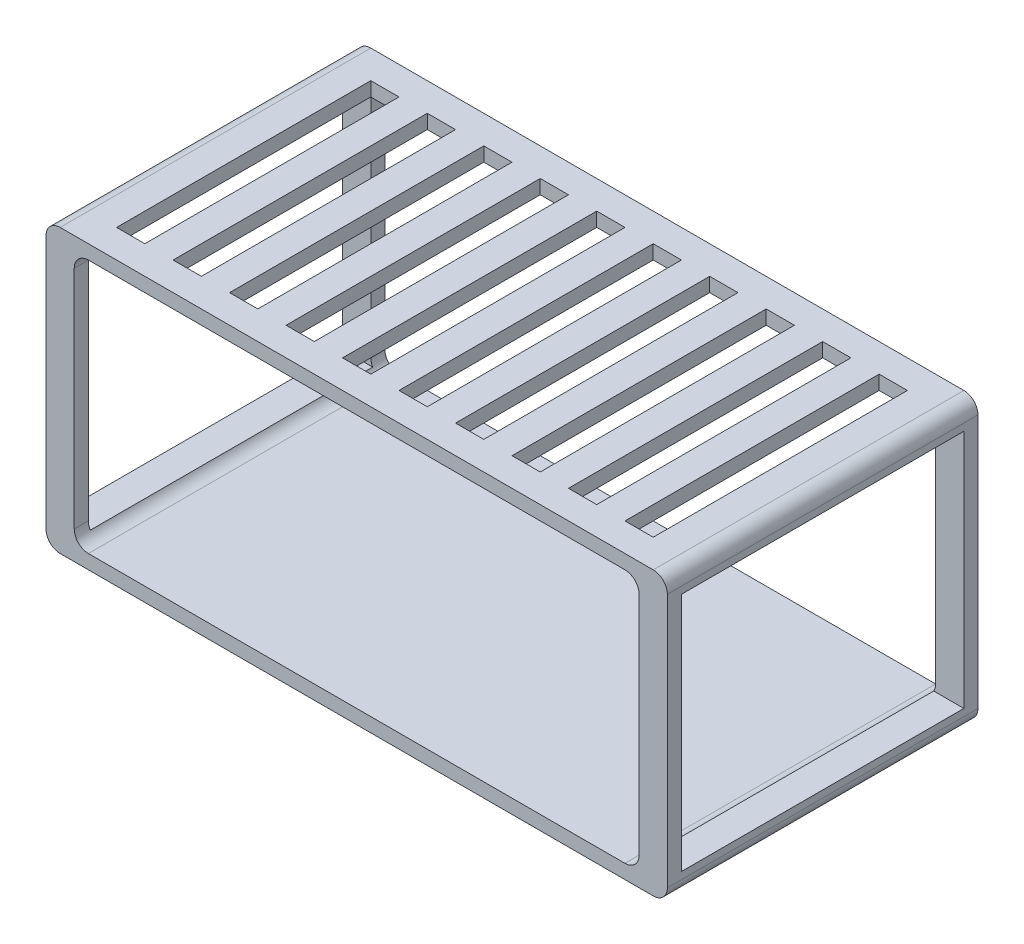
from build123d import *

# Parameters (mm, degrees)
SKETCH1_W               = 2200
SKETCH1_H               = 1000
BOSS_EXTRUDE1_DEPTH     = 1100
SKETCH2_W               = 2000
SKETCH2_H               = 900
CUT_EXTRUDE1_DEPTH      = 1
CUT_EXTRUDE1_DEPTH_BACK = 1101
FILLET1_R               = 50
CUT_EXTRUDE2_REACH      = 1002
SKETCH3_W               = 100
SKETCH3_H               = 900
SKETCH4_W               = 1000
SKETCH4_H               = 850
CUT_EXTRUDE3_DEPTH      = 1
CUT_EXTRUDE3_DEPTH_BACK = 2201


with BuildPart() as part:
    # Sketch1 → Boss-Extrude1 (new body)
    with BuildSketch(Plane.XY):
        with Locations((-1100, 500)):
            Rectangle(SKETCH1_W, SKETCH1_H)
    extrude(amount=BOSS_EXTRUDE1_DEPTH)

    # Sketch2 → Cut-Extrude1 (cut, two sides)
    with BuildSketch(Plane.XY.offset(1100)) as cut_extrude1_sk:
        with Locations((-1100, 500)):
            Rectangle(SKETCH2_W, SKETCH2_H)
    extrude(amount=CUT_EXTRUDE1_DEPTH, mode=Mode.SUBTRACT)
    extrude(cut_extrude1_sk.sketch, amount=-CUT_EXTRUDE1_DEPTH_BACK, mode=Mode.SUBTRACT)

    # Fillet1
    fillet1_edges = [part.edges().sort_by_distance(p)[0] for p in [
        (-2100, 50, 550),
        (-2100, 950, 550),
        (-100, 950, 550),
        (-100, 50, 550),
        (0, 0, 550),
        (-2200, 0, 550),
        (-2200, 1000, 550),
        (0, 1000, 550),
    ]]
    fillet(fillet1_edges, radius=FILLET1_R)

    # Sketch3 → Cut-Extrude2 (cut, up to next)
    with BuildSketch(Plane(origin=(0, 1000, 0), x_dir=(1, 0, 0), z_dir=(0, 1, 0)), mode=Mode.PRIVATE) as cut_extrude2_sk1:
        with Locations((-2000, -550)):
            Rectangle(SKETCH3_W, SKETCH3_H)
    cut_extrude2_tool1 = extrude(cut_extrude2_sk1.sketch, amount=-CUT_EXTRUDE2_REACH, mode=Mode.PRIVATE) & part.part
    add(cut_extrude2_tool1.solids().sort_by_distance((-2000, 1000, 550))[0], mode=Mode.SUBTRACT)
    # Sketch3 → Cut-Extrude2 (cut, up to next)
    with BuildSketch(Plane(origin=(0, 1000, 0), x_dir=(1, 0, 0), z_dir=(0, 1, 0)), mode=Mode.PRIVATE) as cut_extrude2_sk2:
        with Locations((-1800, -550)):
            Rectangle(SKETCH3_W, SKETCH3_H)
    cut_extrude2_tool2 = extrude(cut_extrude2_sk2.sketch, amount=-CUT_EXTRUDE2_REACH, mode=Mode.PRIVATE) & part.part
    add(cut_extrude2_tool2.solids().sort_by_distance((-1800, 1000, 550))[0], mode=Mode.SUBTRACT)
    # Sketch3 → Cut-Extrude2 (cut, up to next)
    with BuildSketch(Plane(origin=(0, 1000, 0), x_dir=(1, 0, 0), z_dir=(0, 1, 0)), mode=Mode.PRIVATE) as cut_extrude2_sk3:
        with Locations((-1600, -550)):
            Rectangle(SKETCH3_W, SKETCH3_H)
    cut_extrude2_tool3 = extrude(cut_extrude2_sk3.sketch, amount=-CUT_EXTRUDE2_REACH, mode=Mode.PRIVATE) & part.part
    add(cut_extrude2_tool3.solids().sort_by_distance((-1600, 1000, 550))[0], mode=Mode.SUBTRACT)
    # Sketch3 → Cut-Extrude2 (cut, up to next)
    with BuildSketch(Plane(origin=(0, 1000, 0), x_dir=(1, 0, 0), z_dir=(0, 1, 0)), mode=Mode.PRIVATE) as cut_extrude2_sk4:
        with Locations((-1400, -550)):
            Rectangle(SKETCH3_W, SKETCH3_H)
    cut_extrude2_tool4 = extrude(cut_extrude2_sk4.sketch, amount=-CUT_EXTRUDE2_REACH, mode=Mode.PRIVATE) & part.part
    add(cut_extrude2_tool4.solids().sort_by_distance((-1400, 1000, 550))[0], mode=Mode.SUBTRACT)
    # Sketch3 → Cut-Extrude2 (cut, up to next)
    with BuildSketch(Plane(origin=(0, 1000, 0), x_dir=(1, 0, 0), z_dir=(0, 1, 0)), mode=Mode.PRIVATE) as cut_extrude2_sk5:
        with Locations((-1200, -550)):
            Rectangle(SKETCH3_W, SKETCH3_H)
    cut_extrude2_tool5 = extrude(cut_extrude2_sk5.sketch, amount=-CUT_EXTRUDE2_REACH, mode=Mode.PRIVATE) & part.part
    add(cut_extrude2_tool5.solids().sort_by_distance((-1200, 1000, 550))[0], mode=Mode.SUBTRACT)
    # Sketch3 → Cut-Extrude2 (cut, up to next)
    with BuildSketch(Plane(origin=(0, 1000, 0), x_dir=(1, 0, 0), z_dir=(0, 1, 0)), mode=Mode.PRIVATE) as cut_extrude2_sk6:
        with Locations((-1000, -550)):
            Rectangle(SKETCH3_W, SKETCH3_H)
    cut_extrude2_tool6 = extrude(cut_extrude2_sk6.sketch, amount=-CUT_EXTRUDE2_REACH, mode=Mode.PRIVATE) & part.part
    add(cut_extrude2_tool6.solids().sort_by_distance((-1000, 1000, 550))[0], mode=Mode.SUBTRACT)
    # Sketch3 → Cut-Extrude2 (cut, up to next)
    with BuildSketch(Plane(origin=(0, 1000, 0), x_dir=(1, 0, 0), z_dir=(0, 1, 0)), mode=Mode.PRIVATE) as cut_extrude2_sk7:
        with Locations((-800, -550)):
            Rectangle(SKETCH3_W, SKETCH3_H)
    cut_extrude2_tool7 = extrude(cut_extrude2_sk7.sketch, amount=-CUT_EXTRUDE2_REACH, mode=Mode.PRIVATE) & part.part
    add(cut_extrude2_tool7.solids().sort_by_distance((-800, 1000, 550))[0], mode=Mode.SUBTRACT)
    # Sketch3 → Cut-Extrude2 (cut, up to next)
    with BuildSketch(Plane(origin=(0, 1000, 0), x_dir=(1, 0, 0), z_dir=(0, 1, 0)), mode=Mode.PRIVATE) as cut_extrude2_sk8:
        with Locations((-600, -550)):
            Rectangle(SKETCH3_W, SKETCH3_H)
    cut_extrude2_tool8 = extrude(cut_extrude2_sk8.sketch, amount=-CUT_EXTRUDE2_REACH, mode=Mode.PRIVATE) & part.part
    add(cut_extrude2_tool8.solids().sort_by_distance((-600, 1000, 550))[0], mode=Mode.SUBTRACT)
    # Sketch3 → Cut-Extrude2 (cut, up to next)
    with BuildSketch(Plane(origin=(0, 1000, 0), x_dir=(1, 0, 0), z_dir=(0, 1, 0)), mode=Mode.PRIVATE) as cut_extrude2_sk9:
        with Locations((-400, -550)):
            Rectangle(SKETCH3_W, SKETCH3_H)
    cut_extrude2_tool9 = extrude(cut_extrude2_sk9.sketch, amount=-CUT_EXTRUDE2_REACH, mode=Mode.PRIVATE) & part.part
    add(cut_extrude2_tool9.solids().sort_by_distance((-400, 1000, 550))[0], mode=Mode.SUBTRACT)
    # Sketch3 → Cut-Extrude2 (cut, up to next)
    with BuildSketch(Plane(origin=(0, 1000, 0), x_dir=(1, 0, 0), z_dir=(0, 1, 0)), mode=Mode.PRIVATE) as cut_extrude2_sk10:
        with Locations((-200, -550)):
            Rectangle(SKETCH3_W, SKETCH3_H)
    cut_extrude2_tool10 = extrude(cut_extrude2_sk10.sketch, amount=-CUT_EXTRUDE2_REACH, mode=Mode.PRIVATE) & part.part
    add(cut_extrude2_tool10.solids().sort_by_distance((-200, 1000, 550))[0], mode=Mode.SUBTRACT)

    # Sketch4 → Cut-Extrude3 (cut, two sides)
    with BuildSketch(Plane(origin=(0, 0, 0), x_dir=(0, 0, -1), z_dir=(1, 0, 0))) as cut_extrude3_sk:
        with Locations((-550, 500)):
            Rectangle(SKETCH4_W, SKETCH4_H)
    extrude(amount=CUT_EXTRUDE3_DEPTH, mode=Mode.SUBTRACT)
    extrude(cut_extrude3_sk.sketch, amount=-CUT_EXTRUDE3_DEPTH_BACK, mode=Mode.SUBTRACT)


solid = part.part
